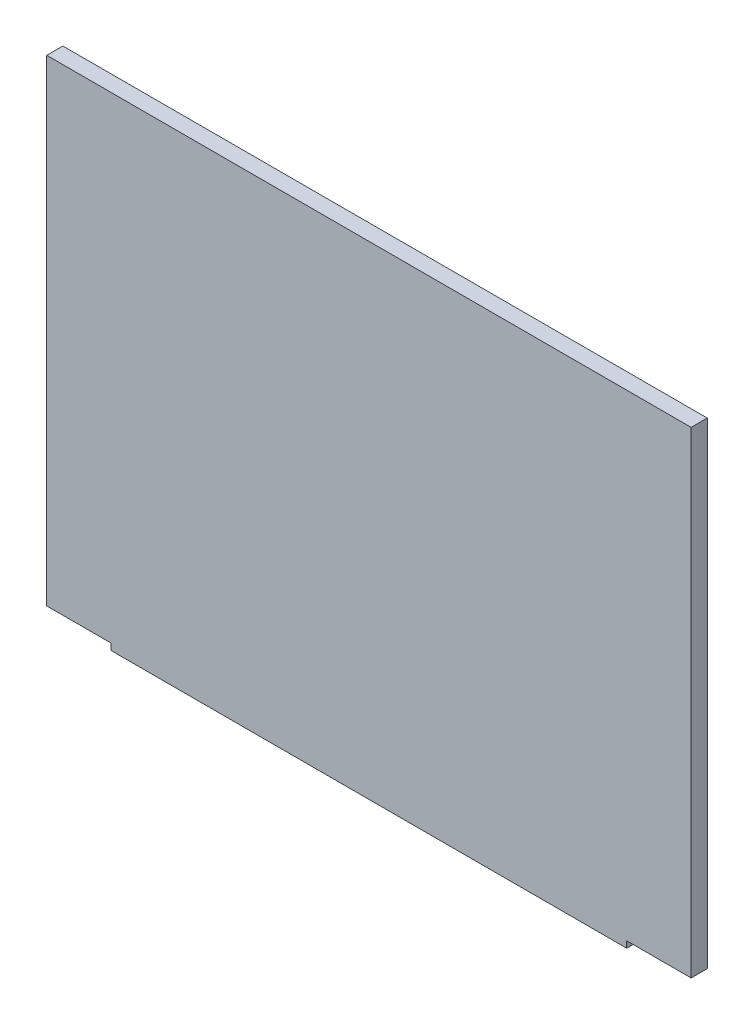
from build123d import *

# Parameters (mm, degrees)
ESQUISSE1_W             = 200
ESQUISSE1_H             = 150
BOSS_EXTRU_1_DEPTH      = 5
ESQUISSE2_W             = 20
ESQUISSE2_H             = 2
ENL_V_MAT_EXTRU_1_DEPTH = 10


with BuildPart() as part:
    # Esquisse1 → Boss.-Extru.1 (new body)
    with BuildSketch(Plane.XY):
        with Locations((88.961529419, -68.018867925)):
            Rectangle(ESQUISSE1_W, ESQUISSE1_H)
    extrude(amount=BOSS_EXTRU_1_DEPTH)

    # Esquisse2 → Enlèv. mat.-Extru.1 (cut)
    with BuildSketch(Plane.XY.offset(5)):
        with Locations((178.961529419, -142.018867925)):
            Rectangle(ESQUISSE2_W, ESQUISSE2_H)
        with Locations((-1.038470581, -142.018867925)):
            Rectangle(ESQUISSE2_W, ESQUISSE2_H)
    extrude(amount=-ENL_V_MAT_EXTRU_1_DEPTH, mode=Mode.SUBTRACT)


solid = part.part
